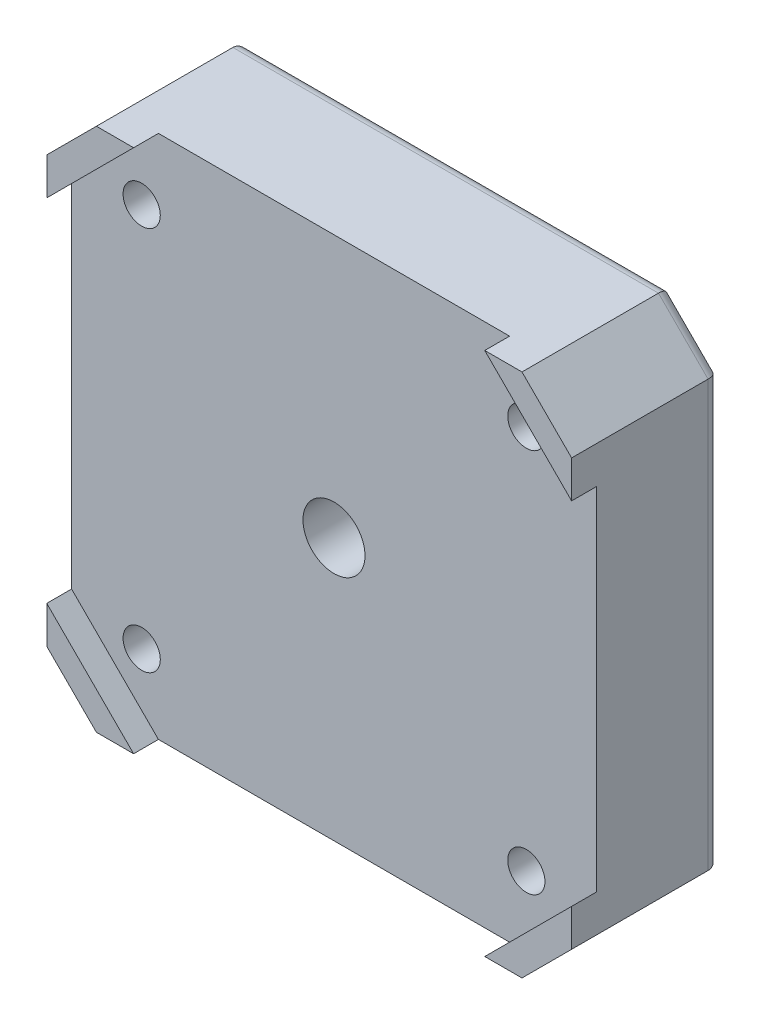
from build123d import *

# Parameters (mm, degrees)
BOSS_EXTRUDE1_DEPTH = 24
CUT_EXTRUDE1_DEPTH  = 4
SKETCH3_R           = 3
CUT_EXTRUDE2_DEPTH  = 21
SKETCH5_R           = 6.2
CUT_EXTRUDE3_DEPTH  = 3
FILLET1_R           = 1
FILLET2_R           = 2
SKETCH6_R           = 11
CUT_EXTRUDE4_DEPTH  = 10
SKETCH7_R           = 5
CUT_EXTRUDE5_DEPTH  = 15
FILLET3_R           = 2


with BuildPart() as part:
    # Sketch1 → Boss-Extrude1 (new body)
    with BuildSketch(Plane.XY):
        Polygon((0, 76.6), (8, 84.6), (76.6, 84.6), (84.6, 76.6), (84.6, 8), (76.6, 0), (8, 0), (0, 8), align=None)
    extrude(amount=BOSS_EXTRUDE1_DEPTH)

    # Sketch2 → Cut-Extrude1 (cut)
    with BuildSketch(Plane.XY.offset(24)):
        Polygon((0, 70.6), (14, 84.6), (70.6, 84.6), (84.6, 70.6), (84.6, 14), (70.6, 0), (14, 0), (0, 14), align=None)
    extrude(amount=-CUT_EXTRUDE1_DEPTH, mode=Mode.SUBTRACT)

    # Sketch3 → Cut-Extrude2 (cut, through all)
    with BuildSketch(Plane.XY.offset(20)):
        with Locations((11.3, 73.3)):
            Circle(SKETCH3_R)
        with Locations((73.3, 73.3)):
            Circle(SKETCH3_R)
        with Locations((73.3, 11.3)):
            Circle(SKETCH3_R)
        with Locations((11.3, 11.3)):
            Circle(SKETCH3_R)
    extrude(amount=-CUT_EXTRUDE2_DEPTH, mode=Mode.SUBTRACT)

    # Sketch5 → Cut-Extrude3 (cut)
    with BuildSketch(Plane(origin=(0, 0, 0), x_dir=(-1, 0, 0), z_dir=(0, 0, -1))):
        with Locations((-73.3, 73.3)):
            Circle(SKETCH5_R)
        with Locations((-11.3, 73.3)):
            Circle(SKETCH5_R)
        with Locations((-11.3, 11.3)):
            Circle(SKETCH5_R)
        with Locations((-73.3, 11.3)):
            Circle(SKETCH5_R)
    extrude(amount=-CUT_EXTRUDE3_DEPTH, mode=Mode.SUBTRACT)

    # Fillet1
    fillet1_edges = [part.edges().sort_by_distance(p)[0] for p in [
        (79.5, 11.3, 0),
        (79.5, 11.3, 3),
        (17.5, 11.3, 0),
        (17.5, 11.3, 3),
        (17.5, 73.3, 0),
        (17.5, 73.3, 3),
        (79.5, 73.3, 0),
        (79.5, 73.3, 3),
    ]]
    fillet(fillet1_edges, radius=FILLET1_R)

    # Fillet2
    fillet2_edges = [part.edges().sort_by_distance(p)[0] for p in [
        (4, 4, 0),
        (0, 42.3, 0),
        (4, 80.6, 0),
        (42.3, 84.6, 0),
        (80.6, 80.6, 0),
        (84.6, 42.3, 0),
        (80.6, 4, 0),
        (42.3, 0, 0),
    ]]
    fillet(fillet2_edges, radius=FILLET2_R)

    # Sketch6 → Cut-Extrude4 (cut)
    with BuildSketch(Plane(origin=(0, 0, 0), x_dir=(-1, 0, 0), z_dir=(0, 0, -1))):
        with Locations((-42.3, 42.3)):
            Circle(SKETCH6_R)
    extrude(amount=-CUT_EXTRUDE4_DEPTH, mode=Mode.SUBTRACT)

    # Sketch7 → Cut-Extrude5 (cut, through all)
    with BuildSketch(Plane(origin=(0, 0, 10), x_dir=(-1, 0, 0), z_dir=(0, 0, -1))):
        with Locations((-42.3, 42.3)):
            Circle(SKETCH7_R)
    extrude(amount=-CUT_EXTRUDE5_DEPTH, mode=Mode.SUBTRACT)

    # Fillet3
    fillet3_edges = [part.edges().sort_by_distance(p)[0] for p in [
        (53.3, 42.3, 10),
        (53.3, 42.3, 0),
    ]]
    fillet(fillet3_edges, radius=FILLET3_R)


solid = part.part
